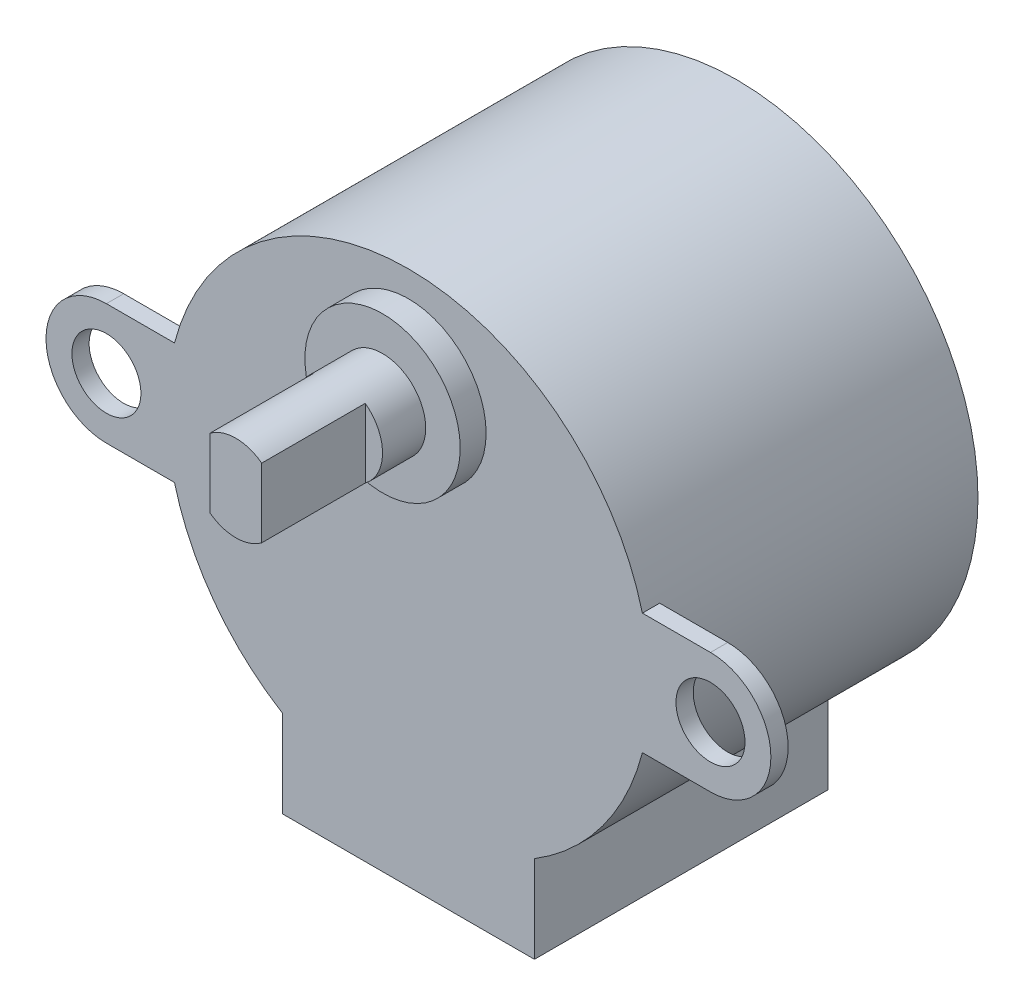
from build123d import *
from build123d.topology import SkipClean

# Parameters (mm, degrees)
SKETCH2_R           = 14
BOSS_EXTRUDE2_DEPTH = 19
SKETCH3_R           = 4.5
BOSS_EXTRUDE3_DEPTH = 1.5
SKETCH4_R           = 2.5
BOSS_EXTRUDE4_DEPTH = 2.5
SKETCH5_R           = 2
BOSS_EXTRUDE5_DEPTH = 1
SKETCH6_W           = 14.6
SKETCH6_H           = 9.231468238
BOSS_EXTRUDE6_DEPTH = 17
BOSS_EXTRUDE7_DEPTH = 6


with BuildPart() as part:
    # Sketch2 → Boss-Extrude2 (new body)
    with BuildSketch(Plane.XY):
        Circle(SKETCH2_R)
    extrude(amount=BOSS_EXTRUDE2_DEPTH)

    # Sketch3 → Boss-Extrude3 (add)
    with BuildSketch(Plane.XY.offset(19)):
        with Locations((0, 8)):
            Circle(SKETCH3_R)
    extrude(amount=BOSS_EXTRUDE3_DEPTH)

    # Sketch4 → Boss-Extrude4 (add)
    with BuildSketch(Plane.XY.offset(20.5)):
        with Locations((0, 8)):
            Circle(SKETCH4_R)
    extrude(amount=BOSS_EXTRUDE4_DEPTH)

    # Sketch5 → Boss-Extrude5 (add)
    with BuildSketch(Plane.XY.offset(19)):
        with BuildLine():
            ThreePointArc((17.5, -3.5), (21, 0), (17.5, 3.5))
            Line((17.5, 3.5), (13.555441712, 3.5))
            ThreePointArc((13.555441712, 3.5), (13.888415748, 1.764060095), (14, 0))
            ThreePointArc((14, 0), (13.888415748, -1.764060095), (13.555441712, -3.5))
            Line((13.555441712, -3.5), (17.5, -3.5))
        make_face()
        with Locations((17.5, 0)):
            Circle(SKETCH5_R, mode=Mode.SUBTRACT)
        with BuildLine():
            ThreePointArc((-13.555441712, -3.5), (-14, 0), (-13.555441712, 3.5))
            Line((-13.555441712, 3.5), (-17.5, 3.5))
            ThreePointArc((-17.5, 3.5), (-21, 0), (-17.5, -3.5))
            Line((-17.5, -3.5), (-13.555441712, -3.5))
        make_face()
        with Locations((-17.5, 0)):
            Circle(SKETCH5_R, mode=Mode.SUBTRACT)
    extrude(amount=-BOSS_EXTRUDE5_DEPTH)

    # Sketch6 → Boss-Extrude6 (add)
    with BuildSketch(Plane.XY.offset(19)):
        with Locations((0, -12.384265881)):
            Rectangle(SKETCH6_W, SKETCH6_H)
    extrude(amount=-BOSS_EXTRUDE6_DEPTH)

    # Sketch7 → Boss-Extrude7 (add)
    with SkipClean():  # the faces are left unmerged after this step: merging them gives an invalid solid
        with BuildSketch(Plane.XY.offset(23)):
            with BuildLine():
                Line((-1.5, 6), (-1.5, 10))
                ThreePointArc((-1.5, 10), (0, 10.5), (1.5, 10))
                Line((1.5, 10), (1.5, 6))
                ThreePointArc((1.5, 6), (0, 5.5), (-1.5, 6))
            make_face()
        extrude(amount=BOSS_EXTRUDE7_DEPTH)


solid = part.part
